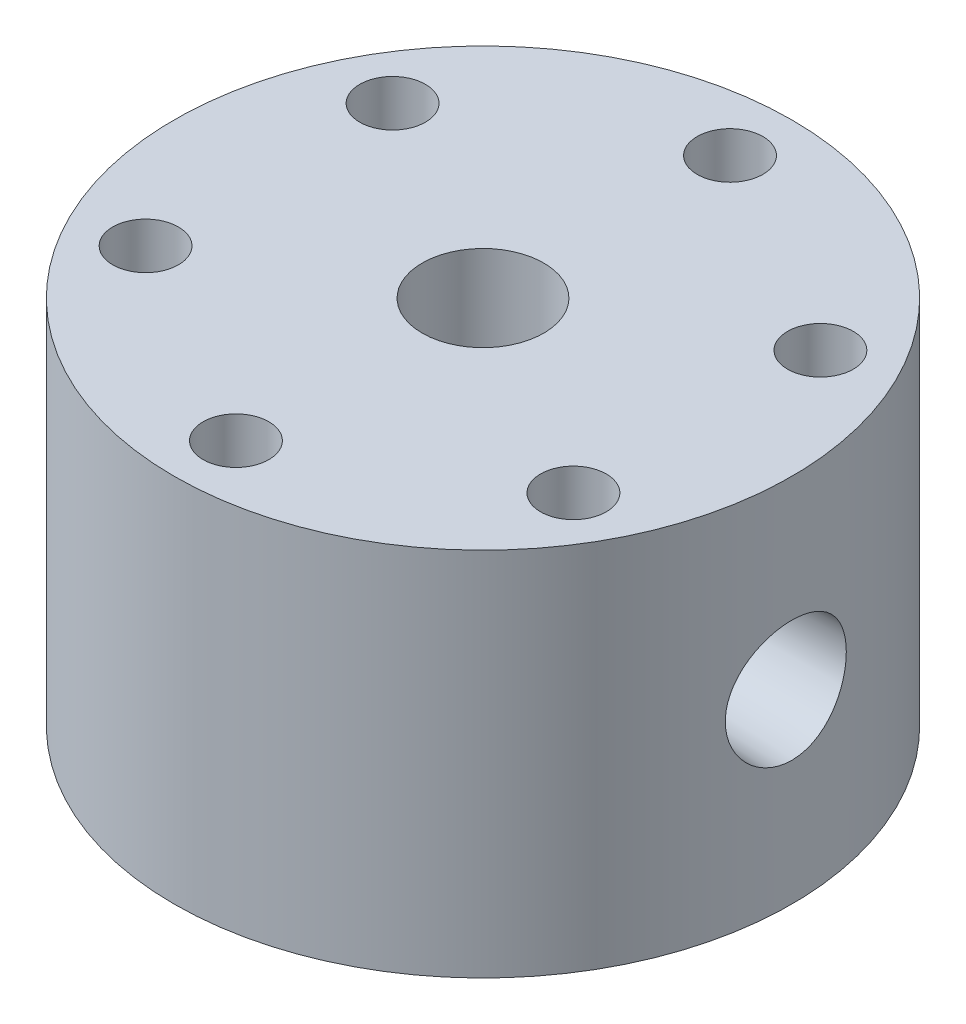
from build123d import *

# Parameters (mm, degrees)
M14X1_5_TAPPED_HOLE1_D              = 12.5
M14X1_5_TAPPED_HOLE1_DEPTH          = 25.4
M14X1_5_TAPPED_HOLE1_TIP            = 3.755378869
F_1_16_0_0625_DIAMETER_HOLE1_D      = 1.5875
F_1_16_0_0625_DIAMETER_HOLE1_DEPTH  = 28.575
F_1_16_0_0625_DIAMETER_HOLE1_TIP    = 0.476933116
F_3_32_0_09375_DIAMETER_HOLE1_D     = 2.38125
F_3_32_0_09375_DIAMETER_HOLE1_DEPTH = 28.702
F_3_32_0_09375_DIAMETER_HOLE1_TIP   = 0.715399675
F_1_4_CLEARANCE_HOLE1_D             = 6.7564
CIRPATTERN1_COUNT                   = 6
F_1_32_0_03125_DIAMETER_HOLE1_D     = 0.79375
F_1_32_0_03125_DIAMETER_HOLE1_DEPTH = 28.575
F_1_32_0_03125_DIAMETER_HOLE1_TIP   = 0.238466558
F_1_8_0_125_DIAMETER_HOLE1_D        = 3.175
F_1_8_0_125_DIAMETER_HOLE1_DEPTH    = 25.4
F_1_8_0_125_DIAMETER_HOLE1_TIP      = 0.953866233


with BuildPart() as part:
    # Sketch1 → Revolve1 (revolve)
    with BuildSketch(Plane.XY):
        Polygon((-20.6375, 0), (-31.75, 0), (-31.75, 38.1), (-3.556, 38.1), (-3.556, 6.35), (-4.7625, 6.35), (-11.1125, 0), (-17.5895, 0), (-17.5895, 2.032), (-20.6375, 2.032), align=None)
    revolve(axis=Axis((0, 0, 0), (0, 1, 0)))

    # M14x1.5 Tapped Hole1
    with Locations(Plane(origin=(0, 38.1, 0), x_dir=(1, 0, 0), z_dir=(0, 1, 0))):
        with Locations((0, 0)):
            Hole(M14X1_5_TAPPED_HOLE1_D / 2, depth=M14X1_5_TAPPED_HOLE1_DEPTH)
            with Locations((0, 0, -(M14X1_5_TAPPED_HOLE1_DEPTH + M14X1_5_TAPPED_HOLE1_TIP / 2))):  # 118° drill point
                Cone(0, M14X1_5_TAPPED_HOLE1_D / 2, M14X1_5_TAPPED_HOLE1_TIP, mode=Mode.SUBTRACT)

    # Sketch6 → 1_4 NPT Tapped Hole1 (revolve, cut)
    with BuildSketch(Plane(origin=(31.75, 19.05, 0), x_dir=(0, 0, -1), z_dir=(0, 1, 0))):
        Polygon((0, 0), (0, 20.360347279), (5.5626, 17.018), (5.5626, 9.906), (5.943685794, 9.906), (6.2402847, 0), align=None)
    revolve(axis=Axis((38.1, 19.05, 0), (-1, 0, 0)), mode=Mode.SUBTRACT)

    # Sketch8 → 1_4 NPT Tapped Hole2 (revolve, cut)
    with BuildSketch(Plane(origin=(-31.75, 19.05, 0), x_dir=(0, 0, 1), z_dir=(0, 1, 0))):
        Polygon((0, 0), (0, 20.360347279), (5.5626, 17.018), (5.5626, 9.906), (5.943685794, 9.906), (6.2402847, 0), align=None)
    revolve(axis=Axis((-38.1, 19.05, 0), (1, 0, 0)), mode=Mode.SUBTRACT)

    # 1_16 _0.0625_ Diameter Hole1
    with Locations(Plane(origin=(31.75, 0, 0), x_dir=(0, 0, -1), z_dir=(1, 0, 0))):
        with Locations((0, 19.05)):
            Hole(F_1_16_0_0625_DIAMETER_HOLE1_D / 2, depth=F_1_16_0_0625_DIAMETER_HOLE1_DEPTH)
            with Locations((0, 0, -(F_1_16_0_0625_DIAMETER_HOLE1_DEPTH + F_1_16_0_0625_DIAMETER_HOLE1_TIP / 2))):  # 118° drill point
                Cone(0, F_1_16_0_0625_DIAMETER_HOLE1_D / 2, F_1_16_0_0625_DIAMETER_HOLE1_TIP, mode=Mode.SUBTRACT)

    # 3_32 _0.09375_ Diameter Hole1
    with Locations(Plane.ZY.offset(31.75)):
        with Locations((0, 19.05)):
            Hole(F_3_32_0_09375_DIAMETER_HOLE1_D / 2, depth=F_3_32_0_09375_DIAMETER_HOLE1_DEPTH)
            with Locations((0, 0, -(F_3_32_0_09375_DIAMETER_HOLE1_DEPTH + F_3_32_0_09375_DIAMETER_HOLE1_TIP / 2))):  # 118° drill point
                Cone(0, F_3_32_0_09375_DIAMETER_HOLE1_D / 2, F_3_32_0_09375_DIAMETER_HOLE1_TIP, mode=Mode.SUBTRACT)

    # 1_4 Clearance Hole1 (through all)
    with Locations(Plane(origin=(0, 38.1, 0), x_dir=(1, 0, 0), z_dir=(0, 1, 0))):
        with Locations((21.997045256, 12.7)):
            f_1_4_clearance_hole1 = Hole(F_1_4_CLEARANCE_HOLE1_D / 2)

    # CirPattern1: 1_4 Clearance Hole1 ×6 about axis
    cirpattern1_axis = Axis((0, 0, 0), (0, -1, 0))
    for i in range(1, CIRPATTERN1_COUNT):
        add(f_1_4_clearance_hole1.rotate(cirpattern1_axis, i * 360 / CIRPATTERN1_COUNT), mode=Mode.SUBTRACT)

    # Sketch18 → 1_4 NPT Tapped Hole3 (revolve, cut)
    with BuildSketch(Plane(origin=(15.875, 19.05, -27.49630657), x_dir=(-0.8660254037844416, 0, -0.49999999999999495), z_dir=(0, 1, 0))):
        Polygon((0, 0), (0, 20.360347279), (5.5626, 17.018), (5.5626, 9.906), (5.943685794, 9.906), (6.2402847, 0), align=None)
    revolve(axis=Axis((19.05, 19.05, -32.995567884), (-0.49999999999999495, 0, 0.8660254037844417)), mode=Mode.SUBTRACT)

    # 1_32 _0.03125_ Diameter Hole1
    with Locations(Plane(origin=(15.875, 0, -27.49630657), x_dir=(0, -1, 0), z_dir=(0.49999999999999495, 0, -0.8660254037844416))):
        with Locations((-19.05, 0)):
            Hole(F_1_32_0_03125_DIAMETER_HOLE1_D / 2, depth=F_1_32_0_03125_DIAMETER_HOLE1_DEPTH)
            with Locations((0, 0, -(F_1_32_0_03125_DIAMETER_HOLE1_DEPTH + F_1_32_0_03125_DIAMETER_HOLE1_TIP / 2))):  # 118° drill point
                Cone(0, F_1_32_0_03125_DIAMETER_HOLE1_D / 2, F_1_32_0_03125_DIAMETER_HOLE1_TIP, mode=Mode.SUBTRACT)

    # 1_8 _0.125_ Diameter Hole1
    with Locations(Plane(origin=(0, 0, 0), x_dir=(0, 0, 1), z_dir=(0.7071067811865512, -0.7071067811865438, 0))):
        with Locations((0, 3.175)):
            Hole(F_1_8_0_125_DIAMETER_HOLE1_D / 2, depth=F_1_8_0_125_DIAMETER_HOLE1_DEPTH)
            with Locations((0, 0, -(F_1_8_0_125_DIAMETER_HOLE1_DEPTH + F_1_8_0_125_DIAMETER_HOLE1_TIP / 2))):  # 118° drill point
                Cone(0, F_1_8_0_125_DIAMETER_HOLE1_D / 2, F_1_8_0_125_DIAMETER_HOLE1_TIP, mode=Mode.SUBTRACT)


solid = part.part
